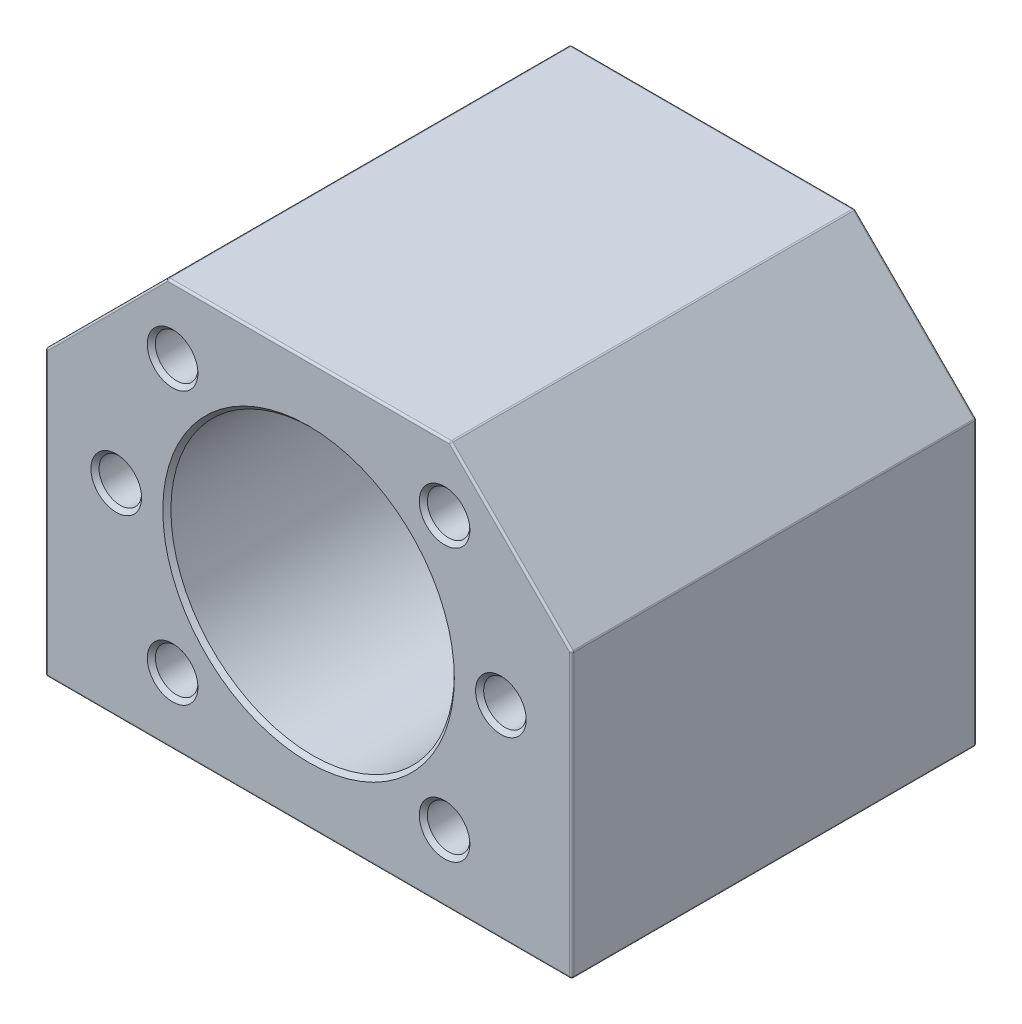
from build123d import *

# Parameters (mm, degrees)
ESQUISSE1_W                  = 52
ESQUISSE1_H                  = 40
ESQUISSE1_R                  = 14
BOSS_EXTRU_1_DEPTH           = 40
CHANFREIN1_SIZE              = 12
TROU_TARAUD_M51_AT_2_COUNT   = 2
TROU_TARAUD_M51_AT_2_PITCH   = 38
R_P_TITION_CIRCULAIRE1_COUNT = 2
R_P_TITION_CIRCULAIRE1_ANGLE = 45
R_P_TITION_CIRCULAIRE2_COUNT = 2
R_P_TITION_CIRCULAIRE2_ANGLE = 315
TROU_TARAUD_M52_D            = 4.2
TROU_TARAUD_M52_DEPTH        = 14
TROU_TARAUD_M52_TIP          = 1.2618073
CONG_1_R                     = 0.2
CHANFREIN2_SIZE              = 0.4


with BuildPart() as part:
    # Esquisse1 → Boss.-Extru.1 (new body)
    with BuildSketch(Plane.XY):
        with Locations((26, 20)):
            Rectangle(ESQUISSE1_W, ESQUISSE1_H)
        with Locations((26, 20)):
            Circle(ESQUISSE1_R, mode=Mode.SUBTRACT)
    extrude(amount=BOSS_EXTRU_1_DEPTH)

    # Chanfrein1
    chanfrein1_edges = [part.edges().sort_by_distance(p)[0] for p in [
        (0, 40, 20),
        (52, 40, 20),
    ]]
    chamfer(chanfrein1_edges, length=CHANFREIN1_SIZE)

    # Esquisse2 → Trou taraudé M51 (revolve, cut)
    with BuildSketch(Plane(origin=(7, 20, 40), x_dir=(0, -1, 0), z_dir=(1, 0, 0))):
        Polygon((0, 0), (0, 15.2618073), (2.1, 14), (2.1, 0), align=None)
    trou_taraud_m51 = revolve(axis=Axis((7, 20, 46.35), (0, 0, -1)), mode=Mode.SUBTRACT)

    # Trou taraudé M51 at 2: Trou taraudé M51 ×2
    with Locations(*[(i * TROU_TARAUD_M51_AT_2_PITCH, 0, 0) for i in range(1, TROU_TARAUD_M51_AT_2_COUNT)]):
        add(trou_taraud_m51, mode=Mode.SUBTRACT)

    # Répétition circulaire1: Trou taraudé M51 ×2 about axis
    r_p_tition_circulaire1_axis = Axis((26, 20, 0), (0, 0, 1))
    for i in range(1, R_P_TITION_CIRCULAIRE1_COUNT):
        add(trou_taraud_m51.rotate(r_p_tition_circulaire1_axis, i * R_P_TITION_CIRCULAIRE1_ANGLE / (R_P_TITION_CIRCULAIRE1_COUNT - 1)), mode=Mode.SUBTRACT)

    # Répétition circulaire1 copy 1 sketch → Répétition circulaire1 copy 1 (revolve, cut)
    with BuildSketch(Plane(origin=(39.435028843, 33.435028843, 40), x_dir=(0.707106781, -0.707106781, 0), z_dir=(0.707106781, 0.707106781, 0))):
        Polygon((0, 0), (0, 15.2618073), (2.1, 14), (2.1, 0), align=None)
    revolve(axis=Axis((39.435028843, 33.435028843, 46.35), (0, 0, -1)), mode=Mode.SUBTRACT)

    # Répétition circulaire2: Trou taraudé M51 ×2 about axis
    r_p_tition_circulaire2_axis = Axis((26, 20, 0), (0, 0, 1))
    for i in range(1, R_P_TITION_CIRCULAIRE2_COUNT):
        add(trou_taraud_m51.rotate(r_p_tition_circulaire2_axis, i * R_P_TITION_CIRCULAIRE2_ANGLE / (R_P_TITION_CIRCULAIRE2_COUNT - 1)), mode=Mode.SUBTRACT)

    # Répétition circulaire2 copy 1 sketch → Répétition circulaire2 copy 1 (revolve, cut)
    with BuildSketch(Plane(origin=(39.435028843, 6.564971157, 40), x_dir=(-0.707106781, -0.707106781, 0), z_dir=(0.707106781, -0.707106781, 0))):
        Polygon((0, 0), (0, 15.2618073), (2.1, 14), (2.1, 0), align=None)
    revolve(axis=Axis((39.435028843, 6.564971157, 46.35), (0, 0, -1)), mode=Mode.SUBTRACT)

    # Trou taraudé M52
    with Locations(Plane(origin=(0, 0, 0), x_dir=(-1, 0, 0), z_dir=(0, -1, 0))):
        with Locations((-46, -32), (-46, -8), (-6, -32), (-6, -8)):
            Hole(TROU_TARAUD_M52_D / 2, depth=TROU_TARAUD_M52_DEPTH)
            with Locations((0, 0, -(TROU_TARAUD_M52_DEPTH + TROU_TARAUD_M52_TIP / 2))):  # 118° drill point
                Cone(0, TROU_TARAUD_M52_D / 2, TROU_TARAUD_M52_TIP, mode=Mode.SUBTRACT)

    # Congé1
    cong_1_edges = [part.edges().sort_by_distance(p)[0] for p in [
        (52, 14, 40),
        (12, 20, 0),
        (0, 14, 0),
        (0, 14, 40),
        (0, 28, 20),
        (26, 40, 0),
        (46, 34, 0),
        (6, 34, 0),
        (26, 40, 40),
        (40, 40, 20),
        (12, 40, 20),
        (46, 34, 40),
        (6, 34, 40),
        (52, 28, 20),
        (52, 14, 0),
        (26, 0, 0),
        (26, 0, 40),
        (52, 0, 20),
        (0, 0, 20),
    ]]
    fillet(cong_1_edges, radius=CONG_1_R)

    # Chanfrein2
    chanfrein2_edges = [part.edges().sort_by_distance(p)[0] for p in [
        (12, 20, 40),
        (45, 22.1, 40),
        (7, 22.1, 40),
        (37.950104602, 34.919953083, 40),
        (11.080046917, 8.049895398, 40),
        (40.919953083, 8.049895398, 40),
        (14.049895398, 34.919953083, 40),
    ]]
    chamfer(chanfrein2_edges, length=CHANFREIN2_SIZE)


solid = part.part
